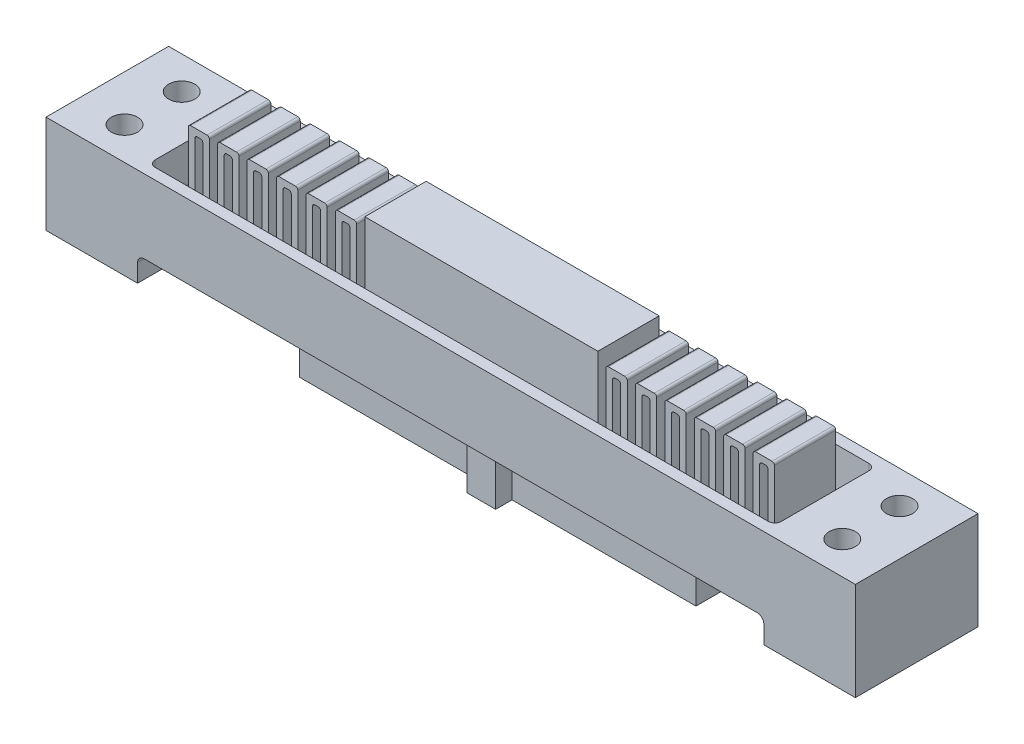
from build123d import *

# Parameters (mm, degrees)
EXTRUDE_1_DEPTH        = 23
CUT_EXTRUDE_1_REACH    = 16.2
SKETCH_3_W             = 10
SKETCH_3_H             = 3.5
EXTRUDE_3_DEPTH        = 3.5
FILLET_1_R             = 0.3
FILLET_1_OF_MIRROR_2_R = 0.3
FILLET_2_R             = 0.3
SKETCH_6_W             = 7.5
SKETCH_6_H             = 23
CUT_EXTRUDE_2_DEPTH    = 11.95
SKETCH_6_2_W           = 7.5
SKETCH_6_2_H           = 23
CUT_EXTRUDE_3_DEPTH    = 1.8
SKETCH_7_W             = 3.5
SKETCH_7_H             = 0.8
EXTRUDE_4_DEPTH        = 1.8
SKETCH_16_W            = 3.5
SKETCH_16_H            = 0.8
EXTRUDE_8_DEPTH        = 1.8
SKETCH_12_W            = 11.2
SKETCH_12_H            = 15
EXTRUDE_7_DEPTH        = 12
SKETCH_14_R            = 1.6
CUT_EXTRUDE_5_DEPTH    = 12
EXTRUDE_9_DEPTH        = 2
EXTRUDE_10_DEPTH       = 2
FILLET_3_R             = 0.6
FILLET_4_R             = 0.6
FILLET_5_R             = 1.2
SKETCH_20_W            = 1.35
SKETCH_20_H            = 9
EXTRUDE_11_DEPTH       = 76.6
FILLET_6_R             = 0.8


with BuildPart() as part:
    # 草图1 → 凸台-拉伸1 (new body)
    with BuildSketch(Plane(origin=(0, 0, 0), x_dir=(1, 0, 0), z_dir=(0, 1, 0))):
        Polygon((-1.75, 1.75), (-24.25, 1.75), (-24.25, -1.75), (-1.75, -1.75), (-1.75, -3.75), (1.75, -3.75), (1.75, -1.75), (24.25, -1.75), (24.25, 1.75), (1.75, 1.75), (1.75, 3.75), (-1.75, 3.75), align=None)
    extrude(amount=EXTRUDE_1_DEPTH)

    # 草图3 → 切除-拉伸1 (cut, up to next)
    with BuildSketch(Plane(origin=(0, 8.8, 0), x_dir=(-1, 0, 0), z_dir=(0, -1, 0)), mode=Mode.PRIVATE) as cut_extrude_1_sk1:
        with Locations((-19.25, 0)):
            Rectangle(SKETCH_3_W, SKETCH_3_H)
    cut_extrude_1_tool1 = extrude(cut_extrude_1_sk1.sketch, amount=-CUT_EXTRUDE_1_REACH, mode=Mode.PRIVATE) & part.part
    add(cut_extrude_1_tool1.solids().sort_by_distance((19.25, 8.8, 0))[0], mode=Mode.SUBTRACT)
    # 草图3 → 切除-拉伸1 (cut, up to next)
    with BuildSketch(Plane(origin=(0, 8.8, 0), x_dir=(-1, 0, 0), z_dir=(0, -1, 0)), mode=Mode.PRIVATE) as cut_extrude_1_sk2:
        with Locations((19.25, 0)):
            Rectangle(SKETCH_3_W, SKETCH_3_H)
    cut_extrude_1_tool2 = extrude(cut_extrude_1_sk2.sketch, amount=-CUT_EXTRUDE_1_REACH, mode=Mode.PRIVATE) & part.part
    add(cut_extrude_1_tool2.solids().sort_by_distance((-19.25, 8.8, 0))[0], mode=Mode.SUBTRACT)

    # 草图4 → 凸台-拉伸3 (add)
    with BuildSketch(Plane.XY.offset(1.75)):
        Polygon((14.25, 11.2), (16.05, 11.2), (16.05, 21.2), (17.05, 21.2), (17.05, 11.2), (17.85, 11.2), (19.65, 11.2), (19.65, 21.2), (20.65, 21.2), (20.65, 11.2), (21.45, 11.2), (23.25, 11.2), (23.25, 21.2), (24.25, 21.2), (24.25, 11.2), (25.05, 11.2), (26.85, 11.2), (26.85, 21.2), (27.85, 21.2), (27.85, 11.2), (28.65, 11.2), (30.45, 11.2), (30.45, 21.2), (31.45, 21.2), (31.45, 11.2), (32.25, 11.2), (34.05, 11.2), (34.05, 21.2), (35.05, 21.2), (35.05, 11.2), (35.85, 11.2), (37.65, 11.2), (37.65, 21.2), (38.65, 21.2), (38.65, 11.2), (39.45, 11.2), (41.25, 11.2), (41.25, 21.2), (42.25, 21.2), (42.25, 11.2), (43.05, 11.2), (44.85, 11.2), (44.85, 21.2), (45.85, 21.2), (45.85, 11.2), (46.65, 11.2), (48.45, 11.2), (48.45, 21.2), (49.45, 21.2), (49.45, 11.2), (50.25, 11.2), (50.25, 12), (50.25, 22), (47.65, 22), (47.65, 12), (46.65, 12), (46.65, 22), (44.05, 22), (44.05, 12), (43.05, 12), (43.05, 22), (40.45, 22), (40.45, 12), (39.45, 12), (39.45, 22), (36.85, 22), (36.85, 12), (35.85, 12), (35.85, 22), (33.25, 22), (33.25, 12), (32.25, 12), (32.25, 22), (29.65, 22), (29.65, 12), (28.65, 12), (28.65, 22), (26.05, 22), (26.05, 12), (25.05, 12), (25.05, 22), (22.45, 22), (22.45, 12), (21.45, 12), (21.45, 22), (18.85, 22), (18.85, 12), (17.85, 12), (17.85, 22), (15.25, 22), (15.25, 12), (14.25, 12), align=None)
    extrude_3 = extrude(amount=-EXTRUDE_3_DEPTH)

    # 圆角1
    fillet_1_edges = [part.edges().sort_by_distance(p)[0] for p in [
        (49.45, 21.2, 0),
        (48.45, 21.2, 0),
        (48.45, 11.2, 0),
        (45.85, 11.2, 0),
        (45.85, 21.2, 0),
        (44.85, 21.2, 0),
        (44.85, 11.2, 0),
        (42.25, 11.2, 0),
        (42.25, 21.2, 0),
        (41.25, 21.2, 0),
        (41.25, 11.2, 0),
        (38.65, 11.2, 0),
        (38.65, 21.2, 0),
        (37.65, 21.2, 0),
        (37.65, 11.2, 0),
        (35.05, 11.2, 0),
        (35.05, 21.2, 0),
        (34.05, 21.2, 0),
        (34.05, 11.2, 0),
        (31.45, 11.2, 0),
        (31.45, 21.2, 0),
        (30.45, 21.2, 0),
        (30.45, 11.2, 0),
        (27.85, 11.2, 0),
        (27.85, 21.2, 0),
        (26.85, 21.2, 0),
        (26.85, 11.2, 0),
        (24.25, 11.2, 0),
        (24.25, 21.2, 0),
        (23.25, 21.2, 0),
        (23.25, 11.2, 0),
        (20.65, 11.2, 0),
        (20.65, 21.2, 0),
        (19.65, 21.2, 0),
        (19.65, 11.2, 0),
        (17.05, 11.2, 0),
        (17.05, 21.2, 0),
        (16.05, 21.2, 0),
        (16.05, 11.2, 0),
        (15.25, 12, 0),
        (15.25, 22, 0),
        (17.85, 22, 0),
        (17.85, 12, 0),
        (18.85, 12, 0),
        (18.85, 22, 0),
        (21.45, 22, 0),
        (21.45, 12, 0),
        (22.45, 12, 0),
        (22.45, 22, 0),
        (25.05, 22, 0),
        (25.05, 12, 0),
        (26.05, 12, 0),
        (26.05, 22, 0),
        (28.65, 22, 0),
        (28.65, 12, 0),
        (29.65, 12, 0),
        (29.65, 22, 0),
        (32.25, 22, 0),
        (32.25, 12, 0),
        (33.25, 12, 0),
        (33.25, 22, 0),
        (35.85, 22, 0),
        (35.85, 12, 0),
        (36.85, 12, 0),
        (36.85, 22, 0),
        (39.45, 22, 0),
        (39.45, 12, 0),
        (40.45, 12, 0),
        (40.45, 22, 0),
        (43.05, 22, 0),
        (43.05, 12, 0),
        (44.05, 12, 0),
        (44.05, 22, 0),
        (46.65, 22, 0),
        (46.65, 12, 0),
        (47.65, 12, 0),
        (47.65, 22, 0),
        (50.25, 22, 0),
    ]]
    fillet(fillet_1_edges, radius=FILLET_1_R)

    # 镜向2: 凸台-拉伸3 across plane
    add(extrude_3.mirror(Plane(origin=(0, 0, 0), x_dir=(0, 0, 1), z_dir=(1, 0, 0))))

    # 圆角1 of 镜向2
    fillet_1_of_mirror_2_edges = [part.edges().sort_by_distance(p)[0] for p in [
        (-49.45, 21.2, 0),
        (-48.45, 21.2, 0),
        (-48.45, 11.2, 0),
        (-45.85, 11.2, 0),
        (-45.85, 21.2, 0),
        (-44.85, 21.2, 0),
        (-44.85, 11.2, 0),
        (-42.25, 11.2, 0),
        (-42.25, 21.2, 0),
        (-41.25, 21.2, 0),
        (-41.25, 11.2, 0),
        (-38.65, 11.2, 0),
        (-38.65, 21.2, 0),
        (-37.65, 21.2, 0),
        (-37.65, 11.2, 0),
        (-35.05, 11.2, 0),
        (-35.05, 21.2, 0),
        (-34.05, 21.2, 0),
        (-34.05, 11.2, 0),
        (-31.45, 11.2, 0),
        (-31.45, 21.2, 0),
        (-30.45, 21.2, 0),
        (-30.45, 11.2, 0),
        (-27.85, 11.2, 0),
        (-27.85, 21.2, 0),
        (-26.85, 21.2, 0),
        (-26.85, 11.2, 0),
        (-24.25, 11.2, 0),
        (-24.25, 21.2, 0),
        (-23.25, 21.2, 0),
        (-23.25, 11.2, 0),
        (-20.65, 11.2, 0),
        (-20.65, 21.2, 0),
        (-19.65, 21.2, 0),
        (-19.65, 11.2, 0),
        (-17.05, 11.2, 0),
        (-17.05, 21.2, 0),
        (-16.05, 21.2, 0),
        (-16.05, 11.2, 0),
        (-15.25, 12, 0),
        (-15.25, 22, 0),
        (-17.85, 22, 0),
        (-17.85, 12, 0),
        (-18.85, 12, 0),
        (-18.85, 22, 0),
        (-21.45, 22, 0),
        (-21.45, 12, 0),
        (-22.45, 12, 0),
        (-22.45, 22, 0),
        (-25.05, 22, 0),
        (-25.05, 12, 0),
        (-26.05, 12, 0),
        (-26.05, 22, 0),
        (-28.65, 22, 0),
        (-28.65, 12, 0),
        (-29.65, 12, 0),
        (-29.65, 22, 0),
        (-32.25, 22, 0),
        (-32.25, 12, 0),
        (-33.25, 12, 0),
        (-33.25, 22, 0),
        (-35.85, 22, 0),
        (-35.85, 12, 0),
        (-36.85, 12, 0),
        (-36.85, 22, 0),
        (-39.45, 22, 0),
        (-39.45, 12, 0),
        (-40.45, 12, 0),
        (-40.45, 22, 0),
        (-43.05, 22, 0),
        (-43.05, 12, 0),
        (-44.05, 12, 0),
        (-44.05, 22, 0),
        (-46.65, 22, 0),
        (-46.65, 12, 0),
        (-47.65, 12, 0),
        (-47.65, 22, 0),
        (-50.25, 22, 0),
    ]]
    fillet(fillet_1_of_mirror_2_edges, radius=FILLET_1_OF_MIRROR_2_R)

    # 圆角2
    fillet_2_edges = [part.edges().sort_by_distance(p)[0] for p in [
        (14.25, 11.2, 0),
        (14.25, 12, 0),
        (-14.25, 11.2, 0),
        (-14.25, 12, 0),
    ]]
    fillet(fillet_2_edges, radius=FILLET_2_R)

    # 草图6 → 切除-拉伸2 (cut)
    with BuildSketch(Plane(origin=(38.3, 0, 0), x_dir=(0, 0, -1), z_dir=(1, 0, 0))):
        with Locations((0, 11.5)):
            Rectangle(SKETCH_6_W, SKETCH_6_H)
    cut_extrude_2 = extrude(amount=CUT_EXTRUDE_2_DEPTH, mode=Mode.SUBTRACT)

    # 草图6<2> → 切除-拉伸3 (cut)
    with BuildSketch(Plane(origin=(38.3, 0, 0), x_dir=(0, 0, -1), z_dir=(1, 0, 0))):
        with Locations((0, 11.5)):
            Rectangle(SKETCH_6_2_W, SKETCH_6_2_H)
    cut_extrude_3 = extrude(amount=-CUT_EXTRUDE_3_DEPTH, mode=Mode.SUBTRACT)

    # 草图7 → 凸台-拉伸4 (add)
    with BuildSketch(Plane(origin=(36.5, 0, 0), x_dir=(0, 0, -1), z_dir=(1, 0, 0))):
        with Locations((0, 11.6)):
            Rectangle(SKETCH_7_W, SKETCH_7_H)
    extrude(amount=EXTRUDE_4_DEPTH)

    # 镜向5: 切除-拉伸2, 切除-拉伸3 across plane
    add(cut_extrude_2.mirror(Plane(origin=(0, 0, 0), x_dir=(0, 0, 1), z_dir=(1, 0, 0))), mode=Mode.SUBTRACT)
    add(cut_extrude_3.mirror(Plane(origin=(0, 0, 0), x_dir=(0, 0, 1), z_dir=(1, 0, 0))), mode=Mode.SUBTRACT)

    # 草图16 → 凸台-拉伸8 (add)
    with BuildSketch(Plane.ZY.offset(36.5)):
        with Locations((0, 11.6)):
            Rectangle(SKETCH_16_W, SKETCH_16_H)
    extrude(amount=EXTRUDE_8_DEPTH)

    # 草图12 → 凸台-拉伸7 (add)
    with BuildSketch(Plane(origin=(0, 5.8, 0), x_dir=(-1, 0, 0), z_dir=(0, -1, 0))):
        with Locations((-43.9, 0)):
            Rectangle(SKETCH_12_W, SKETCH_12_H)
    extrude_7 = extrude(amount=-EXTRUDE_7_DEPTH)

    # 草图14 → 切除-拉伸5 (cut)
    with BuildSketch(Plane(origin=(0, 17.8, 0), x_dir=(1, 0, 0), z_dir=(0, 1, 0))):
        with Locations((43.9, 3.5)):
            Circle(SKETCH_14_R)
        with Locations((43.9, -3.5)):
            Circle(SKETCH_14_R)
    cut_extrude_5 = extrude(amount=-CUT_EXTRUDE_5_DEPTH, mode=Mode.SUBTRACT)

    # 镜向7: 凸台-拉伸7, 切除-拉伸5 across plane
    add(extrude_7.mirror(Plane(origin=(0, 0, 0), x_dir=(0, 0, 1), z_dir=(1, 0, 0))))
    add(cut_extrude_5.mirror(Plane(origin=(0, 0, 0), x_dir=(0, 0, 1), z_dir=(1, 0, 0))), mode=Mode.SUBTRACT)

    # 草图18 → 凸台-拉伸9 (add)
    with BuildSketch(Plane.XY.offset(1.75)):
        with BuildLine():
            Line((-14.25, 8.8), (-1.75, 8.8))
            Line((-1.75, 8.8), (-1.75, 23))
            Line((-1.75, 23), (-14.25, 23))
            Line((-14.25, 23), (-14.25, 12.3))
            ThreePointArc((-14.25, 12.3), (-14.337867966, 12.087867966), (-14.55, 12))
            Line((-14.55, 12), (-14.95, 12))
            ThreePointArc((-14.95, 12), (-15.162132034, 12.087867966), (-15.25, 12.3))
            Line((-15.25, 12.3), (-15.25, 21.7))
            ThreePointArc((-15.25, 21.7), (-15.337867966, 21.912132034), (-15.55, 22))
            Line((-15.55, 22), (-17.55, 22))
            ThreePointArc((-17.55, 22), (-17.762132034, 21.912132034), (-17.85, 21.7))
            Line((-17.85, 21.7), (-17.85, 12.3))
            ThreePointArc((-17.85, 12.3), (-17.937867966, 12.087867966), (-18.15, 12))
            Line((-18.15, 12), (-18.55, 12))
            ThreePointArc((-18.55, 12), (-18.762132034, 12.087867966), (-18.85, 12.3))
            Line((-18.85, 12.3), (-18.85, 21.7))
            ThreePointArc((-18.85, 21.7), (-18.937867966, 21.912132034), (-19.15, 22))
            Line((-19.15, 22), (-21.15, 22))
            ThreePointArc((-21.15, 22), (-21.362132034, 21.912132034), (-21.45, 21.7))
            Line((-21.45, 21.7), (-21.45, 12.3))
            ThreePointArc((-21.45, 12.3), (-21.537867966, 12.087867966), (-21.75, 12))
            Line((-21.75, 12), (-22.15, 12))
            ThreePointArc((-22.15, 12), (-22.362132034, 12.087867966), (-22.45, 12.3))
            Line((-22.45, 12.3), (-22.45, 21.7))
            ThreePointArc((-22.45, 21.7), (-22.537867966, 21.912132034), (-22.75, 22))
            Line((-22.75, 22), (-24.75, 22))
            ThreePointArc((-24.75, 22), (-24.962132034, 21.912132034), (-25.05, 21.7))
            Line((-25.05, 21.7), (-25.05, 12.3))
            ThreePointArc((-25.05, 12.3), (-25.137867966, 12.087867966), (-25.35, 12))
            Line((-25.35, 12), (-25.75, 12))
            ThreePointArc((-25.75, 12), (-25.962132034, 12.087867966), (-26.05, 12.3))
            Line((-26.05, 12.3), (-26.05, 21.7))
            ThreePointArc((-26.05, 21.7), (-26.137867966, 21.912132034), (-26.35, 22))
            Line((-26.35, 22), (-28.35, 22))
            ThreePointArc((-28.35, 22), (-28.562132034, 21.912132034), (-28.65, 21.7))
            Line((-28.65, 21.7), (-28.65, 12.3))
            ThreePointArc((-28.65, 12.3), (-28.737867966, 12.087867966), (-28.95, 12))
            Line((-28.95, 12), (-29.35, 12))
            ThreePointArc((-29.35, 12), (-29.562132034, 12.087867966), (-29.65, 12.3))
            Line((-29.65, 12.3), (-29.65, 21.7))
            ThreePointArc((-29.65, 21.7), (-29.737867966, 21.912132034), (-29.95, 22))
            Line((-29.95, 22), (-31.95, 22))
            ThreePointArc((-31.95, 22), (-32.162132034, 21.912132034), (-32.25, 21.7))
            Line((-32.25, 21.7), (-32.25, 12.3))
            ThreePointArc((-32.25, 12.3), (-32.337867966, 12.087867966), (-32.55, 12))
            Line((-32.55, 12), (-32.95, 12))
            ThreePointArc((-32.95, 12), (-33.162132034, 12.087867966), (-33.25, 12.3))
            Line((-33.25, 12.3), (-33.25, 21.7))
            ThreePointArc((-33.25, 21.7), (-33.337867966, 21.912132034), (-33.55, 22))
            Line((-33.55, 22), (-35.55, 22))
            ThreePointArc((-35.55, 22), (-35.762132034, 21.912132034), (-35.85, 21.7))
            Line((-35.85, 21.7), (-35.85, 12.3))
            ThreePointArc((-35.85, 12.3), (-35.937867966, 12.087867966), (-36.15, 12))
            Line((-36.15, 12), (-38.3, 12))
            Line((-38.3, 12), (-38.3, 11.2))
            Line((-38.3, 11.2), (-35.35, 11.2))
            ThreePointArc((-35.35, 11.2), (-35.137867966, 11.287867966), (-35.05, 11.5))
            Line((-35.05, 11.5), (-35.05, 20.9))
            ThreePointArc((-35.05, 20.9), (-34.962132034, 21.112132034), (-34.75, 21.2))
            Line((-34.75, 21.2), (-34.35, 21.2))
            ThreePointArc((-34.35, 21.2), (-34.137867966, 21.112132034), (-34.05, 20.9))
            Line((-34.05, 20.9), (-34.05, 11.5))
            ThreePointArc((-34.05, 11.5), (-33.962132034, 11.287867966), (-33.75, 11.2))
            Line((-33.75, 11.2), (-31.75, 11.2))
            ThreePointArc((-31.75, 11.2), (-31.537867966, 11.287867966), (-31.45, 11.5))
            Line((-31.45, 11.5), (-31.45, 20.9))
            ThreePointArc((-31.45, 20.9), (-31.362132034, 21.112132034), (-31.15, 21.2))
            Line((-31.15, 21.2), (-30.75, 21.2))
            ThreePointArc((-30.75, 21.2), (-30.537867966, 21.112132034), (-30.45, 20.9))
            Line((-30.45, 20.9), (-30.45, 11.5))
            ThreePointArc((-30.45, 11.5), (-30.362132034, 11.287867966), (-30.15, 11.2))
            Line((-30.15, 11.2), (-28.15, 11.2))
            ThreePointArc((-28.15, 11.2), (-27.937867966, 11.287867966), (-27.85, 11.5))
            Line((-27.85, 11.5), (-27.85, 20.9))
            ThreePointArc((-27.85, 20.9), (-27.762132034, 21.112132034), (-27.55, 21.2))
            Line((-27.55, 21.2), (-27.15, 21.2))
            ThreePointArc((-27.15, 21.2), (-26.937867966, 21.112132034), (-26.85, 20.9))
            Line((-26.85, 20.9), (-26.85, 11.5))
            ThreePointArc((-26.85, 11.5), (-26.762132034, 11.287867966), (-26.55, 11.2))
            Line((-26.55, 11.2), (-24.55, 11.2))
            ThreePointArc((-24.55, 11.2), (-24.337867966, 11.287867966), (-24.25, 11.5))
            Line((-24.25, 11.5), (-24.25, 20.9))
            ThreePointArc((-24.25, 20.9), (-24.162132034, 21.112132034), (-23.95, 21.2))
            Line((-23.95, 21.2), (-23.55, 21.2))
            ThreePointArc((-23.55, 21.2), (-23.337867966, 21.112132034), (-23.25, 20.9))
            Line((-23.25, 20.9), (-23.25, 11.5))
            ThreePointArc((-23.25, 11.5), (-23.162132034, 11.287867966), (-22.95, 11.2))
            Line((-22.95, 11.2), (-20.95, 11.2))
            ThreePointArc((-20.95, 11.2), (-20.737867966, 11.287867966), (-20.65, 11.5))
            Line((-20.65, 11.5), (-20.65, 20.9))
            ThreePointArc((-20.65, 20.9), (-20.562132034, 21.112132034), (-20.35, 21.2))
            Line((-20.35, 21.2), (-19.95, 21.2))
            ThreePointArc((-19.95, 21.2), (-19.737867966, 21.112132034), (-19.65, 20.9))
            Line((-19.65, 20.9), (-19.65, 11.5))
            ThreePointArc((-19.65, 11.5), (-19.562132034, 11.287867966), (-19.35, 11.2))
            Line((-19.35, 11.2), (-17.35, 11.2))
            ThreePointArc((-17.35, 11.2), (-17.137867966, 11.287867966), (-17.05, 11.5))
            Line((-17.05, 11.5), (-17.05, 20.9))
            ThreePointArc((-17.05, 20.9), (-16.962132034, 21.112132034), (-16.75, 21.2))
            Line((-16.75, 21.2), (-16.35, 21.2))
            ThreePointArc((-16.35, 21.2), (-16.137867966, 21.112132034), (-16.05, 20.9))
            Line((-16.05, 20.9), (-16.05, 11.5))
            ThreePointArc((-16.05, 11.5), (-15.962132034, 11.287867966), (-15.75, 11.2))
            Line((-15.75, 11.2), (-14.55, 11.2))
            ThreePointArc((-14.55, 11.2), (-14.337867966, 11.112132034), (-14.25, 10.9))
            Line((-14.25, 10.9), (-14.25, 8.8))
        make_face()
    extrude_9 = extrude(amount=EXTRUDE_9_DEPTH)

    # 草图19 → 凸台-拉伸10 (add)
    with BuildSketch(Plane(origin=(0, 0, -1.75), x_dir=(-1, 0, 0), z_dir=(0, 0, -1))):
        with BuildLine():
            Line((14.25, 8.8), (1.75, 8.8))
            Line((1.75, 8.8), (1.75, 23))
            Line((1.75, 23), (14.25, 23))
            Line((14.25, 23), (14.25, 12.3))
            ThreePointArc((14.25, 12.3), (14.337867966, 12.087867966), (14.55, 12))
            Line((14.55, 12), (14.95, 12))
            ThreePointArc((14.95, 12), (15.162132034, 12.087867966), (15.25, 12.3))
            Line((15.25, 12.3), (15.25, 21.7))
            ThreePointArc((15.25, 21.7), (15.337867966, 21.912132034), (15.55, 22))
            Line((15.55, 22), (17.55, 22))
            ThreePointArc((17.55, 22), (17.762132034, 21.912132034), (17.85, 21.7))
            Line((17.85, 21.7), (17.85, 12.3))
            ThreePointArc((17.85, 12.3), (17.937867966, 12.087867966), (18.15, 12))
            Line((18.15, 12), (18.55, 12))
            ThreePointArc((18.55, 12), (18.762132034, 12.087867966), (18.85, 12.3))
            Line((18.85, 12.3), (18.85, 21.7))
            ThreePointArc((18.85, 21.7), (18.937867966, 21.912132034), (19.15, 22))
            Line((19.15, 22), (21.15, 22))
            ThreePointArc((21.15, 22), (21.362132034, 21.912132034), (21.45, 21.7))
            Line((21.45, 21.7), (21.45, 12.3))
            ThreePointArc((21.45, 12.3), (21.537867966, 12.087867966), (21.75, 12))
            Line((21.75, 12), (22.15, 12))
            ThreePointArc((22.15, 12), (22.362132034, 12.087867966), (22.45, 12.3))
            Line((22.45, 12.3), (22.45, 21.7))
            ThreePointArc((22.45, 21.7), (22.537867966, 21.912132034), (22.75, 22))
            Line((22.75, 22), (24.75, 22))
            ThreePointArc((24.75, 22), (24.962132034, 21.912132034), (25.05, 21.7))
            Line((25.05, 21.7), (25.05, 12.3))
            ThreePointArc((25.05, 12.3), (25.137867966, 12.087867966), (25.35, 12))
            Line((25.35, 12), (25.75, 12))
            ThreePointArc((25.75, 12), (25.962132034, 12.087867966), (26.05, 12.3))
            Line((26.05, 12.3), (26.05, 21.7))
            ThreePointArc((26.05, 21.7), (26.137867966, 21.912132034), (26.35, 22))
            Line((26.35, 22), (28.35, 22))
            ThreePointArc((28.35, 22), (28.562132034, 21.912132034), (28.65, 21.7))
            Line((28.65, 21.7), (28.65, 12.3))
            ThreePointArc((28.65, 12.3), (28.737867966, 12.087867966), (28.95, 12))
            Line((28.95, 12), (29.35, 12))
            ThreePointArc((29.35, 12), (29.562132034, 12.087867966), (29.65, 12.3))
            Line((29.65, 12.3), (29.65, 21.7))
            ThreePointArc((29.65, 21.7), (29.737867966, 21.912132034), (29.95, 22))
            Line((29.95, 22), (31.95, 22))
            ThreePointArc((31.95, 22), (32.162132034, 21.912132034), (32.25, 21.7))
            Line((32.25, 21.7), (32.25, 12.3))
            ThreePointArc((32.25, 12.3), (32.337867966, 12.087867966), (32.55, 12))
            Line((32.55, 12), (32.95, 12))
            ThreePointArc((32.95, 12), (33.162132034, 12.087867966), (33.25, 12.3))
            Line((33.25, 12.3), (33.25, 21.7))
            ThreePointArc((33.25, 21.7), (33.337867966, 21.912132034), (33.55, 22))
            Line((33.55, 22), (35.55, 22))
            ThreePointArc((35.55, 22), (35.762132034, 21.912132034), (35.85, 21.7))
            Line((35.85, 21.7), (35.85, 12.3))
            ThreePointArc((35.85, 12.3), (35.937867966, 12.087867966), (36.15, 12))
            Line((36.15, 12), (38.3, 12))
            Line((38.3, 12), (38.3, 11.2))
            Line((38.3, 11.2), (35.35, 11.2))
            ThreePointArc((35.35, 11.2), (35.137867966, 11.287867966), (35.05, 11.5))
            Line((35.05, 11.5), (35.05, 20.9))
            ThreePointArc((35.05, 20.9), (34.962132034, 21.112132034), (34.75, 21.2))
            Line((34.75, 21.2), (34.35, 21.2))
            ThreePointArc((34.35, 21.2), (34.137867966, 21.112132034), (34.05, 20.9))
            Line((34.05, 20.9), (34.05, 11.5))
            ThreePointArc((34.05, 11.5), (33.962132034, 11.287867966), (33.75, 11.2))
            Line((33.75, 11.2), (31.75, 11.2))
            ThreePointArc((31.75, 11.2), (31.537867966, 11.287867966), (31.45, 11.5))
            Line((31.45, 11.5), (31.45, 20.9))
            ThreePointArc((31.45, 20.9), (31.362132034, 21.112132034), (31.15, 21.2))
            Line((31.15, 21.2), (30.75, 21.2))
            ThreePointArc((30.75, 21.2), (30.537867966, 21.112132034), (30.45, 20.9))
            Line((30.45, 20.9), (30.45, 11.5))
            ThreePointArc((30.45, 11.5), (30.362132034, 11.287867966), (30.15, 11.2))
            Line((30.15, 11.2), (28.15, 11.2))
            ThreePointArc((28.15, 11.2), (27.937867966, 11.287867966), (27.85, 11.5))
            Line((27.85, 11.5), (27.85, 20.9))
            ThreePointArc((27.85, 20.9), (27.762132034, 21.112132034), (27.55, 21.2))
            Line((27.55, 21.2), (27.15, 21.2))
            ThreePointArc((27.15, 21.2), (26.937867966, 21.112132034), (26.85, 20.9))
            Line((26.85, 20.9), (26.85, 11.5))
            ThreePointArc((26.85, 11.5), (26.762132034, 11.287867966), (26.55, 11.2))
            Line((26.55, 11.2), (24.55, 11.2))
            ThreePointArc((24.55, 11.2), (24.337867966, 11.287867966), (24.25, 11.5))
            Line((24.25, 11.5), (24.25, 20.9))
            ThreePointArc((24.25, 20.9), (24.162132034, 21.112132034), (23.95, 21.2))
            Line((23.95, 21.2), (23.55, 21.2))
            ThreePointArc((23.55, 21.2), (23.337867966, 21.112132034), (23.25, 20.9))
            Line((23.25, 20.9), (23.25, 11.5))
            ThreePointArc((23.25, 11.5), (23.162132034, 11.287867966), (22.95, 11.2))
            Line((22.95, 11.2), (20.95, 11.2))
            ThreePointArc((20.95, 11.2), (20.737867966, 11.287867966), (20.65, 11.5))
            Line((20.65, 11.5), (20.65, 20.9))
            ThreePointArc((20.65, 20.9), (20.562132034, 21.112132034), (20.35, 21.2))
            Line((20.35, 21.2), (19.95, 21.2))
            ThreePointArc((19.95, 21.2), (19.737867966, 21.112132034), (19.65, 20.9))
            Line((19.65, 20.9), (19.65, 11.5))
            ThreePointArc((19.65, 11.5), (19.562132034, 11.287867966), (19.35, 11.2))
            Line((19.35, 11.2), (17.35, 11.2))
            ThreePointArc((17.35, 11.2), (17.137867966, 11.287867966), (17.05, 11.5))
            Line((17.05, 11.5), (17.05, 20.9))
            ThreePointArc((17.05, 20.9), (16.962132034, 21.112132034), (16.75, 21.2))
            Line((16.75, 21.2), (16.35, 21.2))
            ThreePointArc((16.35, 21.2), (16.137867966, 21.112132034), (16.05, 20.9))
            Line((16.05, 20.9), (16.05, 11.5))
            ThreePointArc((16.05, 11.5), (15.962132034, 11.287867966), (15.75, 11.2))
            Line((15.75, 11.2), (14.55, 11.2))
            ThreePointArc((14.55, 11.2), (14.337867966, 11.112132034), (14.25, 10.9))
            Line((14.25, 10.9), (14.25, 8.8))
        make_face()
    extrude_10 = extrude(amount=EXTRUDE_10_DEPTH)

    # 镜向9: 凸台-拉伸9, 凸台-拉伸10 across plane
    add(extrude_9.mirror(Plane(origin=(0, 0, 0), x_dir=(0, 0, 1), z_dir=(1, 0, 0))))
    add(extrude_10.mirror(Plane(origin=(0, 0, 0), x_dir=(0, 0, 1), z_dir=(1, 0, 0))))

    # 圆角3
    fillet_3_edges = [part.edges().sort_by_distance(p)[0] for p in [
        (-8, 8.8, 3.75),
        (-8, 8.8, 1.75),
        (-8, 8.8, -3.75),
        (-8, 8.8, -1.75),
        (8, 8.8, 1.75),
        (8, 8.8, 3.75),
        (8, 8.8, -1.75),
        (8, 8.8, -3.75),
    ]]
    fillet(fillet_3_edges, radius=FILLET_3_R)

    # 圆角4
    fillet_4_edges = [part.edges().sort_by_distance(p)[0] for p in [
        (14.25, 8.8, 0),
        (-14.25, 8.8, 0),
    ]]
    fillet(fillet_4_edges, radius=FILLET_4_R)

    # 圆角5
    fillet_5_edges = [part.edges().sort_by_distance(p)[0] for p in [
        (38.3, 11.2, 0),
        (38.3, 12, 0),
        (-38.3, 12, 0),
        (-38.3, 11.2, 0),
        (-38.3, 11.6, 3.75),
        (-38.3, 11.6, -3.75),
        (38.3, 11.6, 3.75),
        (38.3, 11.6, -3.75),
    ]]
    fillet(fillet_5_edges, radius=FILLET_5_R)

    # 草图20 → 凸台-拉伸11 (add)
    with BuildSketch(Plane.ZY.offset(-38.3)):
        with Locations((-6.825, 13.3)):
            Rectangle(SKETCH_20_W, SKETCH_20_H)
    extrude_11 = extrude(amount=EXTRUDE_11_DEPTH)

    # 镜向10: 凸台-拉伸11 across plane
    add(extrude_11.mirror(Plane.XY))

    # 圆角6
    fillet_6_edges = [part.edges().sort_by_distance(p)[0] for p in [
        (-38.3, 8.8, -6.825),
        (-38.3, 13.3, -6.15),
        (38.3, 13.3, -6.15),
        (38.3, 8.8, -6.825),
        (-38.3, 8.8, 6.825),
        (-38.3, 13.3, 6.15),
        (38.3, 8.8, 6.825),
        (38.3, 13.3, 6.15),
    ]]
    fillet(fillet_6_edges, radius=FILLET_6_R)


solid = part.part
